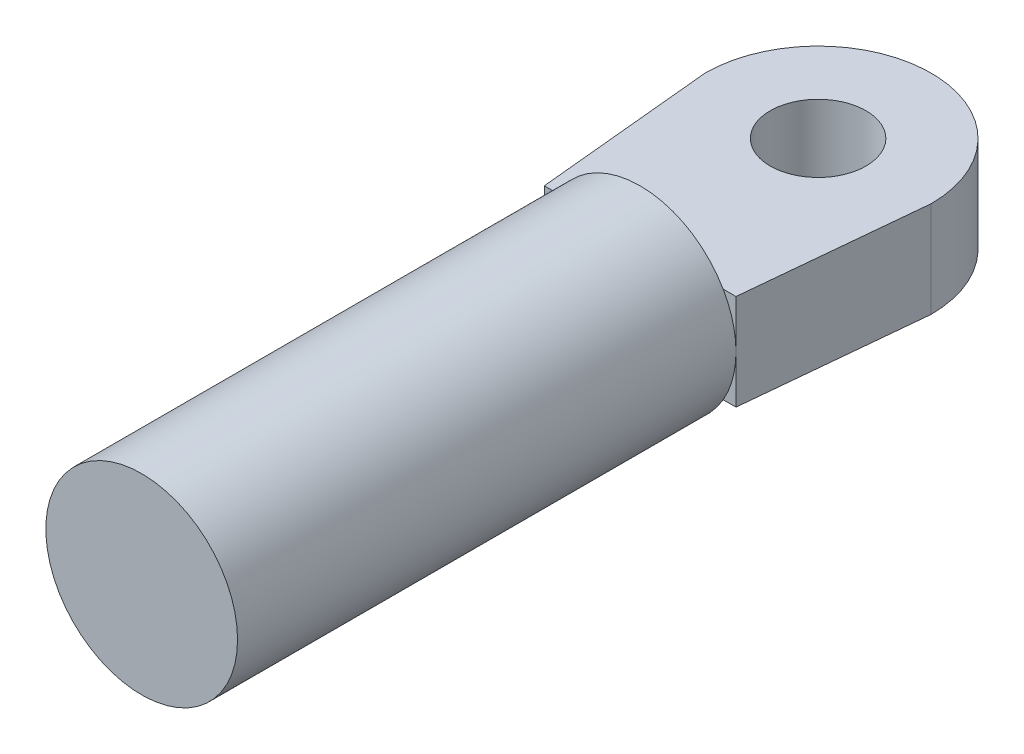
from build123d import *

# Parameters (mm, degrees)
SKETCH_1_R           = 10
EXTRUDE_1_DEPTH      = 52
EXTRUDE_2_DEPTH      = 5
EXTRUDE_2_DEPTH_BACK = 5
SKETCH_2_R           = 5


with BuildPart() as part:
    # Эскиз1 → Бобышка-Вытянуть1 (new body)
    with BuildSketch(Plane.XY):
        Circle(SKETCH_1_R)
    extrude(amount=EXTRUDE_1_DEPTH)

    # Эскиз2 → Бобышка-Вытянуть2 (add, two sides: drawn at the far end of the back side and taken through both)
    with BuildSketch(Plane(origin=(0, 0, 0), x_dir=(1, 0, 0), z_dir=(0, 1, 0)).offset(-EXTRUDE_2_DEPTH_BACK)):
        with BuildLine():
            ThreePointArc((11.798274507, 18.566546971), (0, 30.364821478), (-11.798274507, 18.566546971))
            Line((-11.798274507, 18.566546971), (-11.578972273, 16.302329128))
            Line((-11.578972273, 16.302329128), (-10, 0))
            Line((-10, 0), (10, 0))
            Line((10, 0), (11.578972273, 16.302329128))
            Line((11.578972273, 16.302329128), (11.798274507, 18.566546971))
        make_face()
        with Locations((0, 18.566546971)):
            Circle(SKETCH_2_R, mode=Mode.SUBTRACT)
    extrude(amount=EXTRUDE_2_DEPTH + EXTRUDE_2_DEPTH_BACK)


solid = part.part
